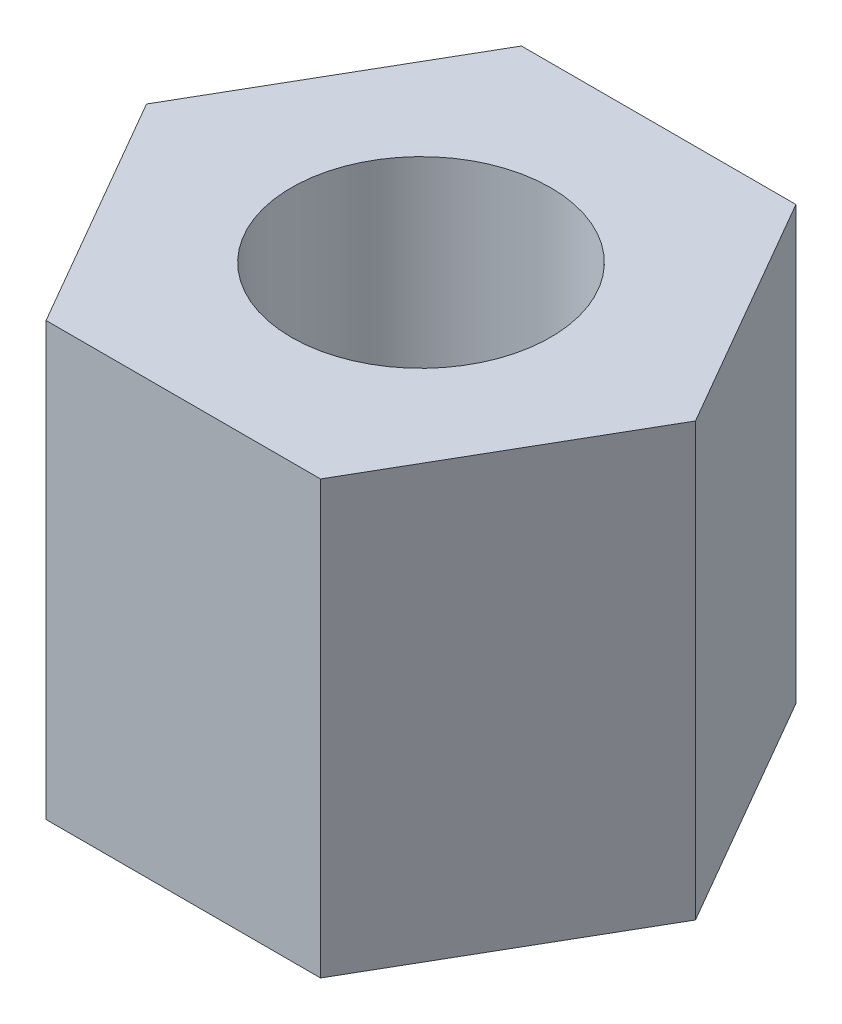
from build123d import *

# Parameters (mm, degrees)
SKETCH1_R           = 1.5
BOSS_EXTRUDE1_DEPTH = 5


with BuildPart() as part:
    # Sketch1 → Boss-Extrude1 (new body)
    with BuildSketch(Plane(origin=(0, 0, 0), x_dir=(1, 0, 0), z_dir=(0, 1, 0))):
        Polygon((3.175426481, 0), (1.58771324, 2.75), (-1.58771324, 2.75), (-3.175426481, 0), (-1.58771324, -2.75), (1.58771324, -2.75), align=None)
        Circle(SKETCH1_R, mode=Mode.SUBTRACT)
    extrude(amount=BOSS_EXTRUDE1_DEPTH)


solid = part.part
